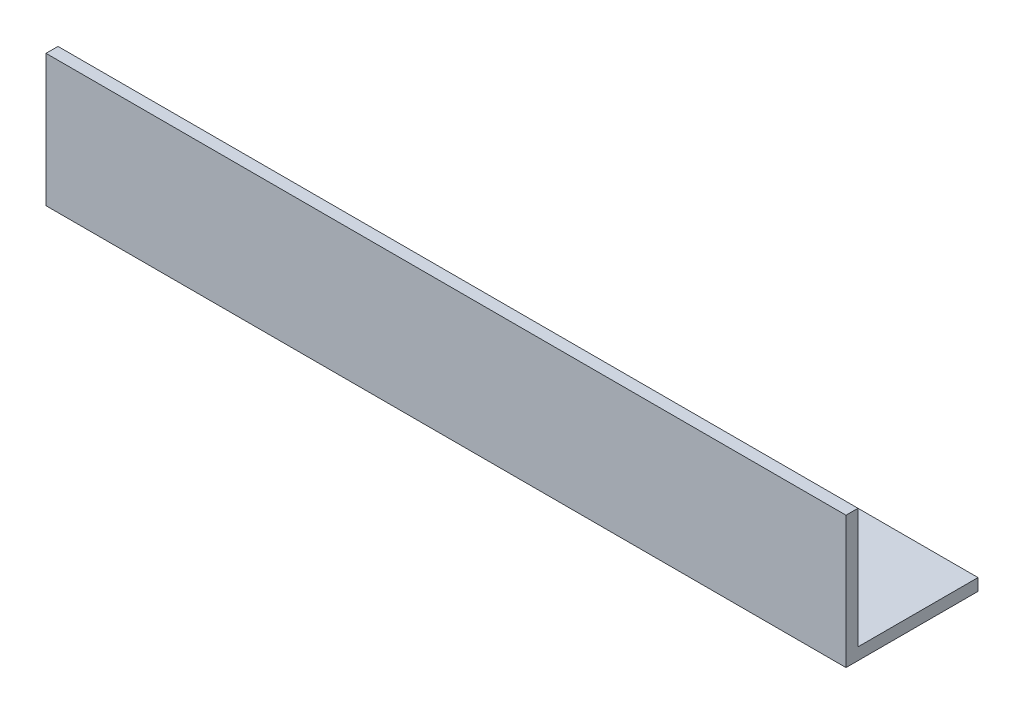
from build123d import *

# Parameters (mm, degrees)
EXTRUDE_1_DEPTH = 200


with BuildPart() as part:
    # Эскиз1 → Вытянуть-Тонкостенный1 (new body)
    with BuildSketch(Plane(origin=(0, 0, 0), x_dir=(0, 0, -1), z_dir=(1, 0, 0))):
        Polygon((0, 33), (0, 0), (33, 0), (33, 3), (3, 3), (3, 33), align=None)
    extrude(amount=EXTRUDE_1_DEPTH)


solid = part.part
